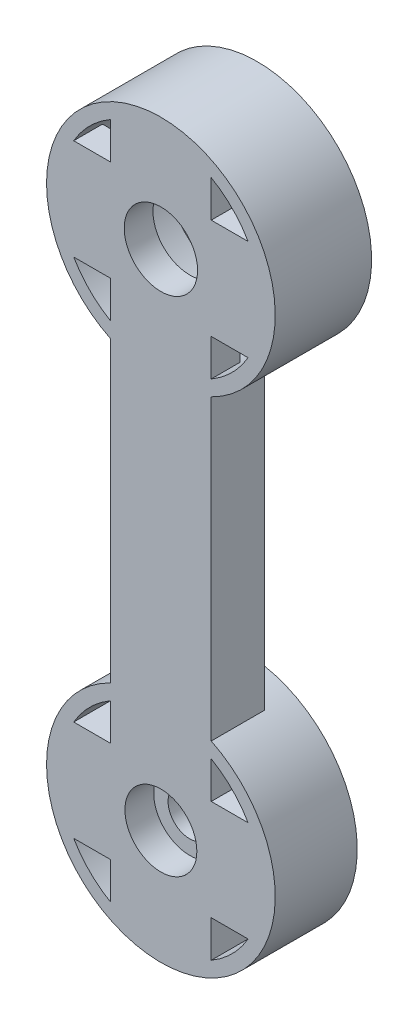
from build123d import *
from build123d.topology import SkipClean

# Parameters (mm, degrees)
SKETCH1_R           = 3.5
SKETCH1_R_2         = 1.5
BOSS_EXTRUDE4_DEPTH = 3
BOSS_EXTRUDE5_START = 3
SKETCH3_R           = 1.5
BOSS_EXTRUDE5_DEPTH = 3
SKETCH4_R           = 2.5
CUT_EXTRUDE1_DEPTH  = 1.5
SKETCH5_R           = 7
CUT_EXTRUDE2_DEPTH  = 4
SKETCH6_R           = 7.95
CUT_EXTRUDE3_DEPTH  = 1
SKETCH7_R           = 2.5
CUT_EXTRUDE4_DEPTH  = 0.5
BOSS_EXTRUDE6_START = 0.7
SKETCH8_R           = 7.95
SKETCH8_R_2         = 7
BOSS_EXTRUDE6_DEPTH = 0.7
BOSS_EXTRUDE8_START = 0.7
SKETCH9_R           = 7.95
SKETCH9_R_2         = 1.5
BOSS_EXTRUDE8_DEPTH = 0.7
BOSS_EXTRUDE9_START = 0.7
BOSS_EXTRUDE9_DEPTH = 0.7
SKETCH11_R          = 2.55
CUT_EXTRUDE5_DEPTH  = 45.190440143


with BuildPart() as part:
    # Sketch1 → Boss-Extrude4 (new body)
    # profile 1 of 34: a face of its own
    with BuildSketch(Plane.XY):
        with BuildLine():
            Line((-3.5, 3.5), (0, 3.5))
            Line((0, 3.5), (3.5, 3.5))
            Line((3.5, 3.5), (3.5, 6.062177826))
            ThreePointArc((3.5, 6.062177826), (0, 7), (-3.5, 6.062177826))
            Line((-3.5, 6.062177826), (-3.5, 3.5))
        make_face()
    # profile 2 of 34: a face of its own
    with BuildSketch(Plane.XY):
        with BuildLine():
            ThreePointArc((3.5, 6.062177826), (4.949747468, 4.949747468), (6.062177826, 3.5))
            Line((6.062177826, 3.5), (7.138101989, 3.5))
            ThreePointArc((7.138101989, 3.5), (0, 7.95), (-7.138101989, 3.5))
            Line((-7.138101989, 3.5), (-6.062177826, 3.5))
            ThreePointArc((-6.062177826, 3.5), (-4.949747468, 4.949747468), (-3.5, 6.062177826))
            ThreePointArc((-3.5, 6.062177826), (0, 7), (3.5, 6.062177826))
        make_face()
    # profile 3 of 34: a face of its own
    with BuildSketch(Plane.XY):
        with BuildLine():
            Line((3.5, -27.861898011), (3.5, -7.138101989))
            ThreePointArc((3.5, -7.138101989), (0, -7.95), (-3.5, -7.138101989))
            Line((-3.5, -7.138101989), (-3.5, -27.861898011))
            ThreePointArc((-3.5, -27.861898011), (0, -27.05), (3.5, -27.861898011))
        make_face()
    # profile 4 of 34: a face of its own
    with BuildSketch(Plane.XY):
        with BuildLine():
            Line((-6.062177826, -38.5), (-7.138101989, -38.5))
            ThreePointArc((-7.138101989, -38.5), (0, -42.95), (7.138101989, -38.5))
            Line((7.138101989, -38.5), (6.062177826, -38.5))
            ThreePointArc((6.062177826, -38.5), (4.949747468, -39.949747468), (3.5, -41.062177826))
            ThreePointArc((3.5, -41.062177826), (0, -42), (-3.5, -41.062177826))
            ThreePointArc((-3.5, -41.062177826), (-4.949747468, -39.949747468), (-6.062177826, -38.5))
        make_face()
    # profile 5 of 34: a face of its own
    with BuildSketch(Plane.XY):
        with BuildLine():
            Line((3.5, -41.062177826), (3.5, -38.5))
            Line((3.5, -38.5), (0, -38.5))
            Line((0, -38.5), (-3.5, -38.5))
            Line((-3.5, -38.5), (-3.5, -41.062177826))
            ThreePointArc((-3.5, -41.062177826), (0, -42), (3.5, -41.062177826))
        make_face()
    # profile 6 of 34: a face of its own
    with BuildSketch(Plane.XY):
        with BuildLine():
            ThreePointArc((7.95, -35), (7.744366043, -33.203532746), (7.138101989, -31.5))
            Line((7.138101989, -31.5), (6.062177826, -31.5))
            ThreePointArc((6.062177826, -31.5), (6.761480784, -33.188266684), (7, -35))
            ThreePointArc((7, -35), (6.761480784, -36.811733316), (6.062177826, -38.5))
            Line((6.062177826, -38.5), (7.138101989, -38.5))
            ThreePointArc((7.138101989, -38.5), (7.744366043, -36.796467254), (7.95, -35))
        make_face()
    # profile 7 of 34: a face of its own
    with BuildSketch(Plane.XY):
        with BuildLine():
            Line((-6.062177826, -31.5), (-7.138101989, -31.5))
            ThreePointArc((-7.138101989, -31.5), (-7.95, -35), (-7.138101989, -38.5))
            Line((-7.138101989, -38.5), (-6.062177826, -38.5))
            ThreePointArc((-6.062177826, -38.5), (-7, -35), (-6.062177826, -31.5))
        make_face()
    # profile 8 of 34: a face of its own
    with BuildSketch(Plane.XY):
        with BuildLine():
            Line((3.5, -38.5), (3.5, -35))
            ThreePointArc((3.5, -35), (2.474873734, -37.474873734), (0, -38.5))
            Line((0, -38.5), (3.5, -38.5))
        make_face()
    # profile 9 of 34: a face of its own
    with BuildSketch(Plane.XY):
        with BuildLine():
            ThreePointArc((0, -38.5), (-2.474873734, -37.474873734), (-3.5, -35))
            Line((-3.5, -35), (-3.5, -38.5))
            Line((-3.5, -38.5), (0, -38.5))
        make_face()
    # profile 10 of 34: a face of its own
    with BuildSketch(Plane.XY):
        with BuildLine():
            ThreePointArc((7.95, -35), (7.744366043, -33.203532746), (7.138101989, -31.5))
            Line((7.138101989, -31.5), (6.062177826, -31.5))
            ThreePointArc((6.062177826, -31.5), (6.761480784, -33.188266684), (7, -35))
            ThreePointArc((7, -35), (6.761480784, -36.811733316), (6.062177826, -38.5))
            Line((6.062177826, -38.5), (7.138101989, -38.5))
            ThreePointArc((7.138101989, -38.5), (7.744366043, -36.796467254), (7.95, -35))
        make_face()
    # profile 11 of 34: a face of its own
    with BuildSketch(Plane.XY):
        with BuildLine():
            Line((-6.062177826, -31.5), (-7.138101989, -31.5))
            ThreePointArc((-7.138101989, -31.5), (-7.95, -35), (-7.138101989, -38.5))
            Line((-7.138101989, -38.5), (-6.062177826, -38.5))
            ThreePointArc((-6.062177826, -38.5), (-7, -35), (-6.062177826, -31.5))
        make_face()
    # profile 12 of 34: a face of its own
    with BuildSketch(Plane.XY):
        with Locations((0, -35)):
            Circle(SKETCH1_R)
        with Locations((0, -35)):
            Circle(SKETCH1_R_2, mode=Mode.SUBTRACT)
    # profile 13 of 34: a face of its own
    with BuildSketch(Plane.XY):
        with BuildLine():
            Line((0, -31.5), (-3.5, -31.5))
            Line((-3.5, -31.5), (-3.5, -35))
            ThreePointArc((-3.5, -35), (-2.474873734, -32.525126266), (0, -31.5))
        make_face()
    # profile 14 of 34: a face of its own
    with BuildSketch(Plane.XY):
        with BuildLine():
            Line((3.5, -35), (3.5, -31.5))
            Line((3.5, -31.5), (0, -31.5))
            ThreePointArc((0, -31.5), (2.474873734, -32.525126266), (3.5, -35))
        make_face()
    # profile 15 of 34: a face of its own
    with BuildSketch(Plane.XY):
        with BuildLine():
            Line((3.5, -31.5), (3.5, -28.937822174))
            ThreePointArc((3.5, -28.937822174), (0, -28), (-3.5, -28.937822174))
            Line((-3.5, -28.937822174), (-3.5, -31.5))
            Line((-3.5, -31.5), (0, -31.5))
            Line((0, -31.5), (3.5, -31.5))
        make_face()
    # profile 16 of 34: a face of its own
    with BuildSketch(Plane.XY):
        with BuildLine():
            Line((-3.5, -28.937822174), (-3.5, -27.861898011))
            ThreePointArc((-3.5, -27.861898011), (-5.62149891, -29.37850109), (-7.138101989, -31.5))
            Line((-7.138101989, -31.5), (-6.062177826, -31.5))
            ThreePointArc((-6.062177826, -31.5), (-4.949747468, -30.050252532), (-3.5, -28.937822174))
        make_face()
    # profile 17 of 34: a face of its own
    with BuildSketch(Plane.XY):
        with BuildLine():
            ThreePointArc((7.138101989, -31.5), (5.62149891, -29.37850109), (3.5, -27.861898011))
            Line((3.5, -27.861898011), (3.5, -28.937822174))
            ThreePointArc((3.5, -28.937822174), (4.949747468, -30.050252532), (6.062177826, -31.5))
            Line((6.062177826, -31.5), (7.138101989, -31.5))
        make_face()
    # profile 18 of 34: a face of its own
    with BuildSketch(Plane.XY):
        with BuildLine():
            Line((3.5, -28.937822174), (3.5, -27.861898011))
            ThreePointArc((3.5, -27.861898011), (0, -27.05), (-3.5, -27.861898011))
            Line((-3.5, -27.861898011), (-3.5, -28.937822174))
            ThreePointArc((-3.5, -28.937822174), (0, -28), (3.5, -28.937822174))
        make_face()
    # profile 19 of 34: a face of its own
    with BuildSketch(Plane.XY):
        with BuildLine():
            Line((-3.5, -35), (-3.5, -31.5))
            Line((-3.5, -31.5), (-6.062177826, -31.5))
            ThreePointArc((-6.062177826, -31.5), (-7, -35), (-6.062177826, -38.5))
            Line((-6.062177826, -38.5), (-3.5, -38.5))
            Line((-3.5, -38.5), (-3.5, -35))
        make_face()
    # profile 20 of 34: a face of its own
    with BuildSketch(Plane.XY):
        with BuildLine():
            Line((6.062177826, -31.5), (3.5, -31.5))
            Line((3.5, -31.5), (3.5, -35))
            Line((3.5, -35), (3.5, -38.5))
            Line((3.5, -38.5), (6.062177826, -38.5))
            ThreePointArc((6.062177826, -38.5), (6.761480784, -36.811733316), (7, -35))
            ThreePointArc((7, -35), (6.761480784, -33.188266684), (6.062177826, -31.5))
        make_face()
    # profile 21 of 34: a face of its own
    with BuildSketch(Plane.XY):
        with BuildLine():
            Line((3.5, -6.062177826), (3.5, -3.5))
            Line((3.5, -3.5), (0, -3.5))
            Line((0, -3.5), (-3.5, -3.5))
            Line((-3.5, -3.5), (-3.5, -6.062177826))
            ThreePointArc((-3.5, -6.062177826), (0, -7), (3.5, -6.062177826))
        make_face()
    # profile 22 of 34: a face of its own
    with BuildSketch(Plane.XY):
        with BuildLine():
            Line((3.5, -7.138101989), (3.5, -6.062177826))
            ThreePointArc((3.5, -6.062177826), (0, -7), (-3.5, -6.062177826))
            Line((-3.5, -6.062177826), (-3.5, -7.138101989))
            ThreePointArc((-3.5, -7.138101989), (0, -7.95), (3.5, -7.138101989))
        make_face()
    # profile 23 of 34: a face of its own
    with BuildSketch(Plane.XY):
        with BuildLine():
            Line((7.138101989, -3.5), (6.062177826, -3.5))
            ThreePointArc((6.062177826, -3.5), (4.949747468, -4.949747468), (3.5, -6.062177826))
            Line((3.5, -6.062177826), (3.5, -7.138101989))
            ThreePointArc((3.5, -7.138101989), (5.62149891, -5.62149891), (7.138101989, -3.5))
        make_face()
    # profile 24 of 34: a face of its own
    with BuildSketch(Plane.XY):
        with BuildLine():
            Line((7.138101989, 3.5), (6.062177826, 3.5))
            ThreePointArc((6.062177826, 3.5), (6.761480784, 1.811733316), (7, 0))
            ThreePointArc((7, 0), (6.761480784, -1.811733316), (6.062177826, -3.5))
            Line((6.062177826, -3.5), (7.138101989, -3.5))
            ThreePointArc((7.138101989, -3.5), (7.744366043, -1.796467254), (7.95, 0))
            ThreePointArc((7.95, 0), (7.744366043, 1.796467254), (7.138101989, 3.5))
        make_face()
    # profile 25 of 34: a face of its own
    with BuildSketch(Plane.XY):
        with BuildLine():
            Line((7.138101989, 3.5), (6.062177826, 3.5))
            ThreePointArc((6.062177826, 3.5), (6.761480784, 1.811733316), (7, 0))
            ThreePointArc((7, 0), (6.761480784, -1.811733316), (6.062177826, -3.5))
            Line((6.062177826, -3.5), (7.138101989, -3.5))
            ThreePointArc((7.138101989, -3.5), (7.744366043, -1.796467254), (7.95, 0))
            ThreePointArc((7.95, 0), (7.744366043, 1.796467254), (7.138101989, 3.5))
        make_face()
    # profile 26 of 34: a face of its own
    with BuildSketch(Plane.XY):
        with BuildLine():
            ThreePointArc((-6.062177826, -3.5), (-7, 0), (-6.062177826, 3.5))
            Line((-6.062177826, 3.5), (-7.138101989, 3.5))
            ThreePointArc((-7.138101989, 3.5), (-7.95, 0), (-7.138101989, -3.5))
            Line((-7.138101989, -3.5), (-6.062177826, -3.5))
        make_face()
    # profile 27 of 34: a face of its own
    with BuildSketch(Plane.XY):
        with BuildLine():
            ThreePointArc((-3.5, -6.062177826), (-4.949747468, -4.949747468), (-6.062177826, -3.5))
            Line((-6.062177826, -3.5), (-7.138101989, -3.5))
            ThreePointArc((-7.138101989, -3.5), (-5.62149891, -5.62149891), (-3.5, -7.138101989))
            Line((-3.5, -7.138101989), (-3.5, -6.062177826))
        make_face()
    # profile 28 of 34: a face of its own
    with BuildSketch(Plane.XY):
        with BuildLine():
            Line((-3.5, 0), (-3.5, 3.5))
            Line((-3.5, 3.5), (-6.062177826, 3.5))
            ThreePointArc((-6.062177826, 3.5), (-7, 0), (-6.062177826, -3.5))
            Line((-6.062177826, -3.5), (-3.5, -3.5))
            Line((-3.5, -3.5), (-3.5, 0))
        make_face()
    # profile 29 of 34: a face of its own
    with BuildSketch(Plane.XY):
        with BuildLine():
            Line((6.062177826, 3.5), (3.5, 3.5))
            Line((3.5, 3.5), (3.5, 0))
            Line((3.5, 0), (3.5, -3.5))
            Line((3.5, -3.5), (6.062177826, -3.5))
            ThreePointArc((6.062177826, -3.5), (6.761480784, -1.811733316), (7, 0))
            ThreePointArc((7, 0), (6.761480784, 1.811733316), (6.062177826, 3.5))
        make_face()
    # profile 30 of 34: a face of its own
    with BuildSketch(Plane.XY):
        with BuildLine():
            Line((3.5, -3.5), (3.5, 0))
            ThreePointArc((3.5, 0), (2.474873734, -2.474873734), (0, -3.5))
            Line((0, -3.5), (3.5, -3.5))
        make_face()
    # profile 31 of 34: a face of its own
    with BuildSketch(Plane.XY):
        Circle(SKETCH1_R)
        Circle(SKETCH1_R_2, mode=Mode.SUBTRACT)
    # profile 32 of 34: a face of its own
    with BuildSketch(Plane.XY):
        with BuildLine():
            ThreePointArc((0, -3.5), (-2.474873734, -2.474873734), (-3.5, 0))
            Line((-3.5, 0), (-3.5, -3.5))
            Line((-3.5, -3.5), (0, -3.5))
        make_face()
    # profile 33 of 34: a face of its own
    with BuildSketch(Plane.XY):
        with BuildLine():
            ThreePointArc((-3.5, 0), (-2.474873734, 2.474873734), (0, 3.5))
            Line((0, 3.5), (-3.5, 3.5))
            Line((-3.5, 3.5), (-3.5, 0))
        make_face()
    # profile 34 of 34: a face of its own
    with BuildSketch(Plane.XY):
        with BuildLine():
            Line((3.5, 3.5), (0, 3.5))
            ThreePointArc((0, 3.5), (2.474873734, 2.474873734), (3.5, 0))
            Line((3.5, 0), (3.5, 3.5))
        make_face()
    extrude(amount=BOSS_EXTRUDE4_DEPTH)

    # Sketch3 → Boss-Extrude5 (add)
    # profile 1 of 4: a face of its own
    with SkipClean():  # the faces are left unmerged after this step: merging them gives an invalid solid
        with BuildSketch(Plane(origin=(0, 0, 0), x_dir=(-1, 0, 0), z_dir=(0, 0, -1)).offset(BOSS_EXTRUDE5_START)):
            with BuildLine():
                ThreePointArc((3.5, -7.138101989), (6.746387922, -4.205799567), (7.95, 0))
                ThreePointArc((7.95, 0), (-4.205799567, 6.746387922), (-3.5, -7.138101989))
                ThreePointArc((-3.5, -7.138101989), (0, -7.95), (3.5, -7.138101989))
            make_face()
            with BuildLine():
                ThreePointArc((-6.062177826, 3.5), (-4.949747468, 4.949747468), (-3.5, 6.062177826))
                ThreePointArc((-3.5, 6.062177826), (0, 7), (3.5, 6.062177826))
                ThreePointArc((3.5, 6.062177826), (4.949747468, 4.949747468), (6.062177826, 3.5))
                ThreePointArc((6.062177826, 3.5), (6.761480784, 1.811733316), (7, 0))
                ThreePointArc((7, 0), (6.761480784, -1.811733316), (6.062177826, -3.5))
                ThreePointArc((6.062177826, -3.5), (4.949747468, -4.949747468), (3.5, -6.062177826))
                ThreePointArc((3.5, -6.062177826), (0, -7), (-3.5, -6.062177826))
                ThreePointArc((-3.5, -6.062177826), (-4.949747468, -4.949747468), (-6.062177826, -3.5))
                ThreePointArc((-6.062177826, -3.5), (-7, 0), (-6.062177826, 3.5))
            make_face(mode=Mode.SUBTRACT)
        # profile 2 of 4: a face of its own
        with BuildSketch(Plane(origin=(0, 0, 0), x_dir=(-1, 0, 0), z_dir=(0, 0, -1)).offset(BOSS_EXTRUDE5_START)):
            with BuildLine():
                ThreePointArc((3.5, 6.062177826), (0, 7), (-3.5, 6.062177826))
                Line((-3.5, 6.062177826), (-3.5, 3.5))
                Line((-3.5, 3.5), (-6.062177826, 3.5))
                ThreePointArc((-6.062177826, 3.5), (-7, 0), (-6.062177826, -3.5))
                Line((-6.062177826, -3.5), (-3.5, -3.5))
                Line((-3.5, -3.5), (-3.5, -6.062177826))
                ThreePointArc((-3.5, -6.062177826), (0, -7), (3.5, -6.062177826))
                Line((3.5, -6.062177826), (3.5, -3.5))
                Line((3.5, -3.5), (6.062177826, -3.5))
                ThreePointArc((6.062177826, -3.5), (6.761480784, -1.811733316), (7, 0))
                ThreePointArc((7, 0), (6.761480784, 1.811733316), (6.062177826, 3.5))
                Line((6.062177826, 3.5), (3.5, 3.5))
                Line((3.5, 3.5), (3.5, 6.062177826))
            make_face()
            Circle(SKETCH3_R, mode=Mode.SUBTRACT)
        # profile 3 of 4: a face of its own
        with BuildSketch(Plane(origin=(0, 0, 0), x_dir=(-1, 0, 0), z_dir=(0, 0, -1)).offset(BOSS_EXTRUDE5_START)):
            with BuildLine():
                ThreePointArc((-3.5, -27.861898011), (-4.205799567, -41.746387922), (7.95, -35))
                ThreePointArc((7.95, -35), (6.746387922, -30.794200433), (3.5, -27.861898011))
                ThreePointArc((3.5, -27.861898011), (0, -27.05), (-3.5, -27.861898011))
            make_face()
            with BuildLine():
                ThreePointArc((6.062177826, -38.5), (4.949747468, -39.949747468), (3.5, -41.062177826))
                ThreePointArc((3.5, -41.062177826), (0, -42), (-3.5, -41.062177826))
                ThreePointArc((-3.5, -41.062177826), (-4.949747468, -39.949747468), (-6.062177826, -38.5))
                ThreePointArc((-6.062177826, -38.5), (-7, -35), (-6.062177826, -31.5))
                ThreePointArc((-6.062177826, -31.5), (-4.949747468, -30.050252532), (-3.5, -28.937822174))
                ThreePointArc((-3.5, -28.937822174), (0, -28), (3.5, -28.937822174))
                ThreePointArc((3.5, -28.937822174), (4.949747468, -30.050252532), (6.062177826, -31.5))
                ThreePointArc((6.062177826, -31.5), (6.761480784, -33.188266684), (7, -35))
                ThreePointArc((7, -35), (6.761480784, -36.811733316), (6.062177826, -38.5))
            make_face(mode=Mode.SUBTRACT)
        # profile 4 of 4: a face of its own
        with BuildSketch(Plane(origin=(0, 0, 0), x_dir=(-1, 0, 0), z_dir=(0, 0, -1)).offset(BOSS_EXTRUDE5_START)):
            with BuildLine():
                ThreePointArc((-3.5, -41.062177826), (0, -42), (3.5, -41.062177826))
                Line((3.5, -41.062177826), (3.5, -38.5))
                Line((3.5, -38.5), (6.062177826, -38.5))
                ThreePointArc((6.062177826, -38.5), (6.761480784, -36.811733316), (7, -35))
                ThreePointArc((7, -35), (6.761480784, -33.188266684), (6.062177826, -31.5))
                Line((6.062177826, -31.5), (3.5, -31.5))
                Line((3.5, -31.5), (3.5, -28.937822174))
                ThreePointArc((3.5, -28.937822174), (0, -28), (-3.5, -28.937822174))
                Line((-3.5, -28.937822174), (-3.5, -31.5))
                Line((-3.5, -31.5), (-6.062177826, -31.5))
                ThreePointArc((-6.062177826, -31.5), (-7, -35), (-6.062177826, -38.5))
                Line((-6.062177826, -38.5), (-3.5, -38.5))
                Line((-3.5, -38.5), (-3.5, -41.062177826))
            make_face()
            with Locations((0, -35)):
                Circle(SKETCH3_R, mode=Mode.SUBTRACT)
        extrude(amount=-BOSS_EXTRUDE5_DEPTH)

    # Sketch4 → Cut-Extrude1 (cut)
    with SkipClean():  # the faces are left unmerged after this step: merging them gives an invalid solid
        with BuildSketch(Plane.XY.offset(3)):
            with Locations((0, -35)):
                Circle(SKETCH4_R)
            with Locations(Location((0, 0, 0), (0, 0, 180))):
                Circle(SKETCH4_R)
        extrude(amount=-CUT_EXTRUDE1_DEPTH, mode=Mode.SUBTRACT)

    # Sketch5 → Cut-Extrude2 (cut)
    with SkipClean():  # the faces are left unmerged after this step: merging them gives an invalid solid
        with BuildSketch(Plane(origin=(0, 0, -3), x_dir=(-1, 0, 0), z_dir=(0, 0, -1))):
            Circle(SKETCH5_R)
        extrude(amount=-CUT_EXTRUDE2_DEPTH, mode=Mode.SUBTRACT)

    # Sketch6 → Cut-Extrude3 (cut)
    with SkipClean():  # the faces are left unmerged after this step: merging them gives an invalid solid
        with BuildSketch(Plane(origin=(0, 0, -3), x_dir=(-1, 0, 0), z_dir=(0, 0, -1))):
            with Locations((0, -35)):
                Circle(SKETCH6_R)
        extrude(amount=-CUT_EXTRUDE3_DEPTH, mode=Mode.SUBTRACT)

    # Sketch7 → Cut-Extrude4 (cut)
    with SkipClean():  # the faces are left unmerged after this step: merging them gives an invalid solid
        with BuildSketch(Plane.XY.offset(1.5)):
            with Locations((0, -35)):
                Circle(SKETCH7_R)
        extrude(amount=-CUT_EXTRUDE4_DEPTH, mode=Mode.SUBTRACT)

    # Sketch8 → Boss-Extrude6 (add)
    with SkipClean():  # the faces are left unmerged after this step: merging them gives an invalid solid
        with BuildSketch(Plane(origin=(0, 0, -3), x_dir=(-1, 0, 0), z_dir=(0, 0, -1)).offset(BOSS_EXTRUDE6_START)):
            Circle(SKETCH8_R)
            Circle(SKETCH8_R_2, mode=Mode.SUBTRACT)
        extrude(amount=-BOSS_EXTRUDE6_DEPTH)

    # Sketch9 → Boss-Extrude8 (add)
    # profile 1 of 2: a face of its own
    with SkipClean():  # the faces are left unmerged after this step: merging them gives an invalid solid
        with BuildSketch(Plane(origin=(0, 0, -2), x_dir=(-1, 0, 0), z_dir=(0, 0, -1)).offset(BOSS_EXTRUDE8_START)):
            with Locations((0, -35)):
                Circle(SKETCH9_R)
            with BuildLine():
                ThreePointArc((-6.062177826, -31.5), (-4.949747468, -30.050252532), (-3.5, -28.937822174))
                ThreePointArc((-3.5, -28.937822174), (0, -28), (3.5, -28.937822174))
                ThreePointArc((3.5, -28.937822174), (4.949747468, -30.050252532), (6.062177826, -31.5))
                ThreePointArc((6.062177826, -31.5), (6.761480784, -33.188266684), (7, -35))
                ThreePointArc((7, -35), (6.761480784, -36.811733316), (6.062177826, -38.5))
                ThreePointArc((6.062177826, -38.5), (4.949747468, -39.949747468), (3.5, -41.062177826))
                ThreePointArc((3.5, -41.062177826), (0, -42), (-3.5, -41.062177826))
                ThreePointArc((-3.5, -41.062177826), (-4.949747468, -39.949747468), (-6.062177826, -38.5))
                ThreePointArc((-6.062177826, -38.5), (-7, -35), (-6.062177826, -31.5))
            make_face(mode=Mode.SUBTRACT)
        # profile 2 of 2: a face of its own
        with BuildSketch(Plane(origin=(0, 0, -2), x_dir=(-1, 0, 0), z_dir=(0, 0, -1)).offset(BOSS_EXTRUDE8_START)):
            with BuildLine():
                ThreePointArc((3.5, -28.937822174), (0, -28), (-3.5, -28.937822174))
                Line((-3.5, -28.937822174), (-3.5, -31.5))
                Line((-3.5, -31.5), (-6.062177826, -31.5))
                ThreePointArc((-6.062177826, -31.5), (-7, -35), (-6.062177826, -38.5))
                Line((-6.062177826, -38.5), (-3.5, -38.5))
                Line((-3.5, -38.5), (-3.5, -41.062177826))
                ThreePointArc((-3.5, -41.062177826), (0, -42), (3.5, -41.062177826))
                Line((3.5, -41.062177826), (3.5, -38.5))
                Line((3.5, -38.5), (6.062177826, -38.5))
                ThreePointArc((6.062177826, -38.5), (6.761480784, -36.811733316), (7, -35))
                ThreePointArc((7, -35), (6.761480784, -33.188266684), (6.062177826, -31.5))
                Line((6.062177826, -31.5), (3.5, -31.5))
                Line((3.5, -31.5), (3.5, -28.937822174))
            make_face()
            with Locations((0, -35)):
                Circle(SKETCH9_R_2, mode=Mode.SUBTRACT)
        extrude(amount=-BOSS_EXTRUDE8_DEPTH)

    # Sketch10 → Boss-Extrude9 (add)
    with SkipClean():  # the faces are left unmerged after this step: merging them gives an invalid solid
        with BuildSketch(Plane(origin=(0, 0, 0), x_dir=(-1, 0, 0), z_dir=(0, 0, -1)).offset(BOSS_EXTRUDE9_START)):
            with BuildLine():
                ThreePointArc((3.5, -7.138101989), (0, -7.95), (-3.5, -7.138101989))
                Line((-3.5, -7.138101989), (-3.5, -27.861898011))
                ThreePointArc((-3.5, -27.861898011), (0, -27.05), (3.5, -27.861898011))
                Line((3.5, -27.861898011), (3.5, -7.138101989))
            make_face()
        extrude(amount=-BOSS_EXTRUDE9_DEPTH)

    # Sketch11 → Cut-Extrude5 (cut, through all)
    with SkipClean():  # the faces are left unmerged after this step: merging them gives an invalid solid
        with BuildSketch(Plane.XY.offset(3)):
            Circle(SKETCH11_R)
        extrude(amount=-CUT_EXTRUDE5_DEPTH, mode=Mode.SUBTRACT)


solid = part.part
